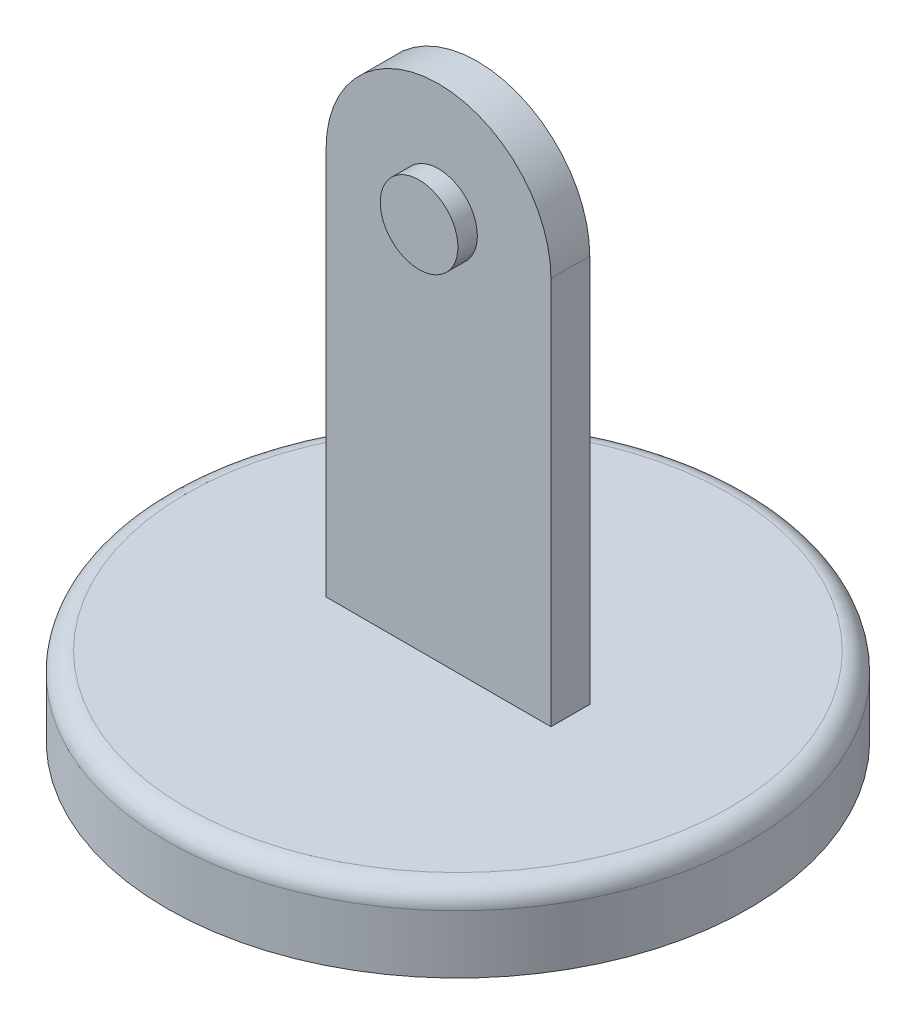
from build123d import *

# Parameters (mm, degrees)
SKETCH1_R                = 75
BOSS_EXTRUDE1_DEPTH      = 20
FILLET1_R                = 5
BOSS_EXTRUDE2_DEPTH      = 5
BOSS_EXTRUDE2_DEPTH_BACK = 5
BOSS_EXTRUDE4_DEPTH      = 10
CUT_EXTRUDE2_DEPTH       = 5
CUT_EXTRUDE2_DEPTH_BACK  = 5
SKETCH4_R                = 5


with BuildPart() as part:
    # Sketch1 → Boss-Extrude1 (new body)
    with BuildSketch(Plane(origin=(0, 0, 0), x_dir=(1, 0, 0), z_dir=(0, 1, 0))):
        Circle(SKETCH1_R)
    extrude(amount=BOSS_EXTRUDE1_DEPTH)

    # Fillet1
    fillet1_edges = [part.edges().sort_by_distance(p)[0] for p in [
        (-75, 20, 0),
    ]]
    fillet(fillet1_edges, radius=FILLET1_R)

    # Sketch2 → Boss-Extrude2 (add, two sides: drawn at the far end of the back side and taken through both)
    with BuildSketch(Plane.XY.offset(-BOSS_EXTRUDE2_DEPTH_BACK)):
        with BuildLine():
            Line((-28.958565119, 120), (-28.958565119, 20))
            Line((-28.958565119, 20), (28.958565119, 20))
            Line((28.958565119, 20), (28.958565119, 120))
            ThreePointArc((28.958565119, 120), (0, 148.958565119), (-28.958565119, 120))
        make_face()
    extrude(amount=BOSS_EXTRUDE2_DEPTH + BOSS_EXTRUDE2_DEPTH_BACK)

    # Sketch3 → Boss-Extrude4 (add)
    with BuildSketch(Plane.XY):
        with BuildLine():
            ThreePointArc((0, 110), (7.071067812, 112.928932188), (10, 120))
            ThreePointArc((10, 120), (-7.071067812, 127.071067812), (0, 110))
        make_face()
    extrude(amount=BOSS_EXTRUDE4_DEPTH)

    # Sketch4 → Cut-Extrude2 (cut, two sides: drawn at the far end of the back side and taken through both)
    with BuildSketch(Plane.XY.offset(-CUT_EXTRUDE2_DEPTH_BACK)):
        with Locations((0, 120)):
            Circle(SKETCH4_R)
    extrude(amount=CUT_EXTRUDE2_DEPTH + CUT_EXTRUDE2_DEPTH_BACK, mode=Mode.SUBTRACT)


solid = part.part
